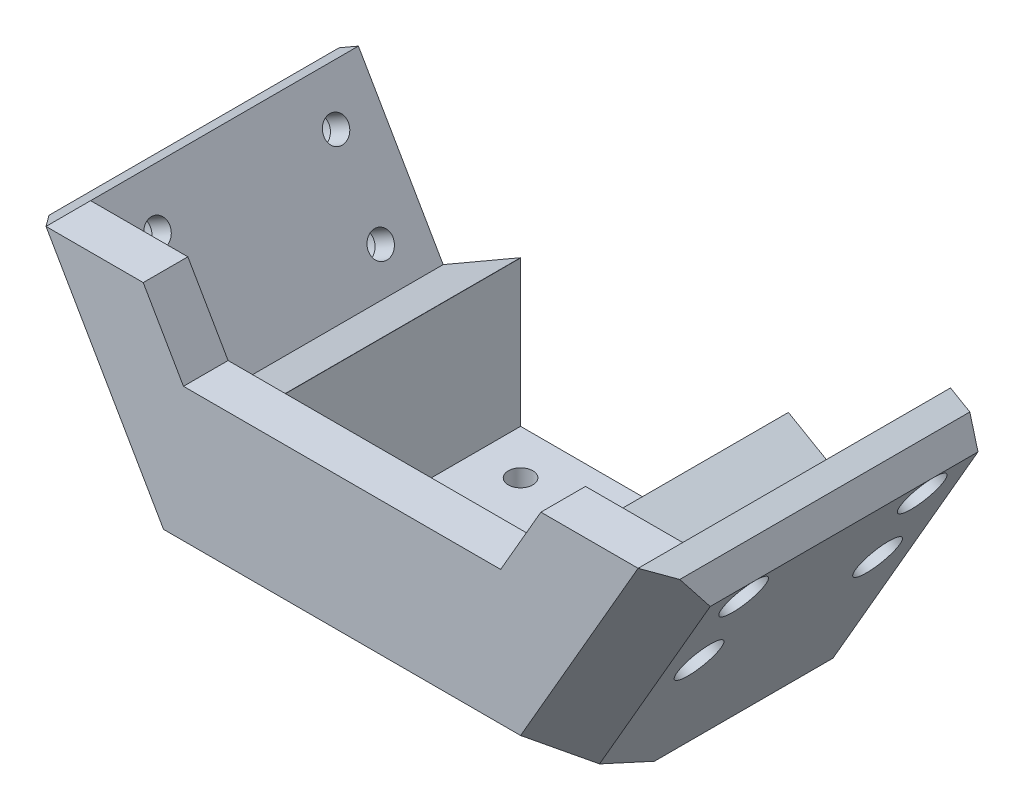
from build123d import *

# Parameters (mm, degrees)
BOSS_EXTRUDE1_DEPTH = 70
CUT_EXTRUDE1_DEPTH  = 60
CHAMFER2_SIZE       = 30
CHAMFER2_SIZE2      = 20
SKETCH4_W           = 60
SKETCH4_H           = 20
CUT_EXTRUDE3_DEPTH  = 40
CUT_EXTRUDE4_DEPTH  = 60
CUT_EXTRUDE7_DEPTH  = 60
CHAMFER5_SIZE       = 5
SKETCH8_R           = 2.75
CUT_EXTRUDE8_DEPTH  = 66.621778265
SKETCH9_R           = 2.75
CUT_EXTRUDE9_DEPTH  = 131.238747058
SKETCH10_R          = 5
CUT_EXTRUDE10_DEPTH = 5
SKETCH11_R          = 5
CUT_EXTRUDE11_DEPTH = 5
CHAMFER6_SIZE       = 10


with BuildPart() as part:
    # Sketch1 → Boss-Extrude1 (new body)
    with BuildSketch(Plane.XY):
        Polygon((-40, -20), (-75, 40.621778265), (-40.358983849, 60.621778265), (-22.679491924, 30), (22.679491924, 30), (40.358983849, 60.621778265), (75, 40.621778265), (40, -20), align=None)
    extrude(amount=BOSS_EXTRUDE1_DEPTH)

    # Sketch2 → Cut-Extrude1 (cut)
    with BuildSketch(Plane(origin=(0, 0, 0), x_dir=(-1, 0, 0), z_dir=(0, 0, -1))):
        Polygon((66.339745962, 45.621778265), (47.339745962, 12.712812921), (30.019237886, 22.712812921), (49.019237886, 55.621778265), align=None)
        Polygon((-47.339745962, 12.712812921), (-30.019237886, 22.712812921), (-49.019237886, 55.621778265), (-66.339745962, 45.621778265), align=None)
    extrude(amount=-CUT_EXTRUDE1_DEPTH, mode=Mode.SUBTRACT)

    # Chamfer2
    chamfer2_edges = [part.edges().sort_by_distance(p)[0] for p in [
        (0, -20, 70),
    ]]
    chamfer2_side = [part.faces().sort_by_distance(p)[0] for p in [
        (0, -20, 35),
    ]]
    chamfer(chamfer2_edges, length=CHAMFER2_SIZE, length2=CHAMFER2_SIZE2, reference=chamfer2_side[0])

    # Sketch4 → Cut-Extrude3 (cut)
    with BuildSketch(Plane(origin=(0, 0, 0), x_dir=(-1, 0, 0), z_dir=(0, 0, -1))):
        Rectangle(SKETCH4_W, SKETCH4_H)
    extrude(amount=-CUT_EXTRUDE3_DEPTH, mode=Mode.SUBTRACT)

    # Sketch5 → Cut-Extrude4 (cut)
    with BuildSketch(Plane(origin=(0, 0, 0), x_dir=(-1, 0, 0), z_dir=(0, 0, -1))):
        Polygon((30, 10), (30, 22.679491924), (49.019237886, 55.621778265), (40.358983849, 60.621778265), (-40.358983849, 60.621778265), (-49.019237886, 55.621778265), (-30, 22.679491924), (-30, 10), align=None)
    extrude(amount=-CUT_EXTRUDE4_DEPTH, mode=Mode.SUBTRACT)

    # Sketch7 → Cut-Extrude7 (cut)
    with BuildSketch(Plane.XY.offset(70)):
        Polygon((66.339745962, 45.621778265), (44.553418013, 45.621778265), (35.534180126, 30), (-35.534180126, 30), (-44.553418013, 45.621778265), (-66.339745962, 45.621778265), (-40.358983849, 60.621778265), (40.358983849, 60.621778265), align=None)
    extrude(amount=-CUT_EXTRUDE7_DEPTH, mode=Mode.SUBTRACT)

    # Chamfer5
    chamfer5_edges = [part.edges().sort_by_distance(p)[0] for p in [
        (75, 40.621778265, 35),
        (-75, 40.621778265, 35),
    ]]
    chamfer(chamfer5_edges, length=CHAMFER5_SIZE)

    # Sketch8 → Cut-Extrude8 (cut, through all)
    with BuildSketch(Plane.XZ.offset(20)):
        with Locations((20, 10)):
            Circle(SKETCH8_R)
        with Locations((20, 30)):
            Circle(SKETCH8_R)
        with Locations((-20, 30)):
            Circle(SKETCH8_R)
        with Locations((-20, 10)):
            Circle(SKETCH8_R)
    extrude(amount=-CUT_EXTRUDE8_DEPTH, mode=Mode.SUBTRACT)

    # Sketch9 → Cut-Extrude9 (cut, through all)
    with BuildSketch(Plane(origin=(38.660254038, -22.320508076, 0), x_dir=(0, 0, -1), z_dir=(0.866025404, -0.5, 0))):
        with Locations((-10, 62.679491924)):
            Circle(SKETCH9_R)
        with Locations((-10, 42.679491924)):
            Circle(SKETCH9_R)
        with Locations((-50, 42.679491924)):
            Circle(SKETCH9_R)
        with Locations((-50, 62.679491924)):
            Circle(SKETCH9_R)
    cut_extrude9 = extrude(amount=-CUT_EXTRUDE9_DEPTH, mode=Mode.SUBTRACT)

    # Mirror1: Cut-Extrude9 across plane
    add(cut_extrude9.mirror(Plane(origin=(0, 0, 0), x_dir=(0, 0, 1), z_dir=(1, 0, 0))), mode=Mode.SUBTRACT)

    # Sketch10 → Cut-Extrude10 (cut)
    with BuildSketch(Plane.XZ.offset(20)):
        with Locations((20, 10)):
            Circle(SKETCH10_R)
        with Locations((20, 30)):
            Circle(SKETCH10_R)
        with Locations((-20, 30)):
            Circle(SKETCH10_R)
        with Locations((-20, 10)):
            Circle(SKETCH10_R)
    extrude(amount=-CUT_EXTRUDE10_DEPTH, mode=Mode.SUBTRACT)

    # Sketch11 → Cut-Extrude11 (cut)
    with BuildSketch(Plane(origin=(38.660254038, -22.320508076, 0), x_dir=(0, 0, -1), z_dir=(0.866025404, -0.5, 0))):
        with Locations((-10, 42.679491924)):
            Circle(SKETCH11_R)
        with Locations((-10, 62.679491924)):
            Circle(SKETCH11_R)
        with Locations((-50, 62.679491924)):
            Circle(SKETCH11_R)
        with Locations((-50, 42.679491924)):
            Circle(SKETCH11_R)
    cut_extrude11 = extrude(amount=-CUT_EXTRUDE11_DEPTH, mode=Mode.SUBTRACT)

    # Mirror2: Cut-Extrude11 across plane
    add(cut_extrude11.mirror(Plane(origin=(0, 0, 0), x_dir=(0, 0, 1), z_dir=(1, 0, 0))), mode=Mode.SUBTRACT)

    # Chamfer6
    chamfer6_edges = [part.edges().sort_by_distance(p)[0] for p in [
        (62.023502692, 18.145825623, 70),
        (-62.023502692, 18.145825623, 70),
    ]]
    chamfer(chamfer6_edges, length=CHAMFER6_SIZE)


solid = part.part
